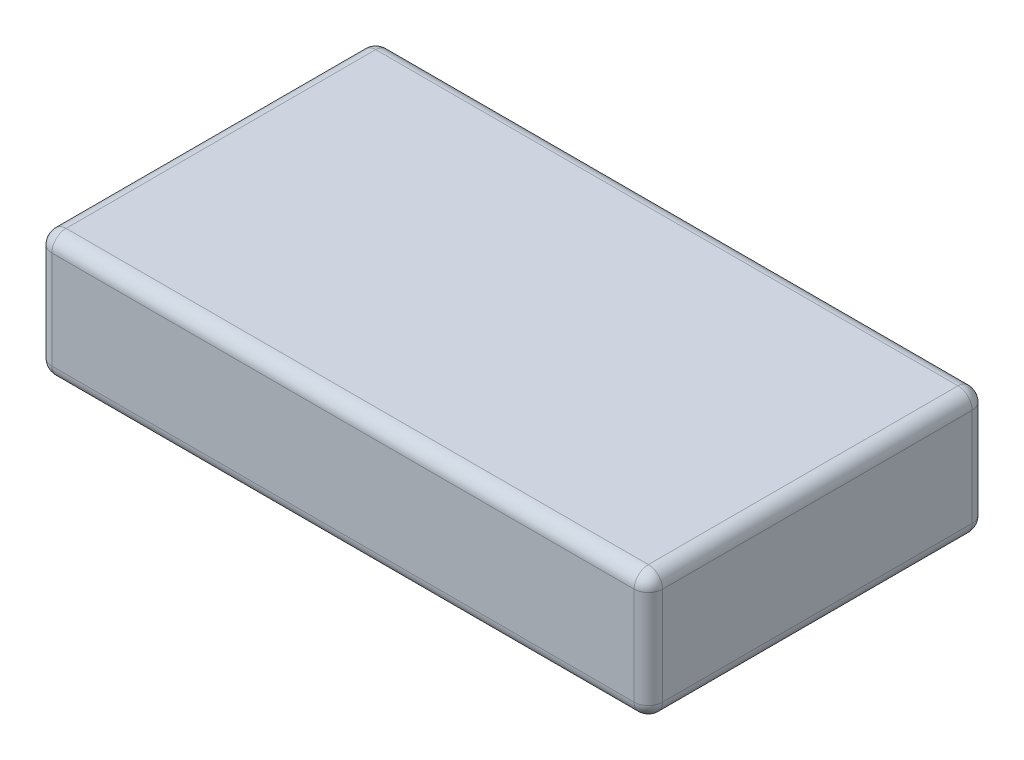
from build123d import *

# Parameters (mm, degrees)
BOSS_EXTRUDE1_DEPTH = 8.89
FILLET1_R           = 1


with BuildPart() as part:
    # Sketch1 → Boss-Extrude1 (new body)
    with BuildSketch(Plane(origin=(0, 0, 0), x_dir=(1, 0, 0), z_dir=(0, 1, 0))):
        with BuildLine():
            Line((-20.5, -11.9), (20.5, -11.9))
            ThreePointArc((20.5, -11.9), (21.207106781, -11.607106781), (21.5, -10.9))
            Line((21.5, -10.9), (21.5, 10.9))
            ThreePointArc((21.5, 10.9), (21.207106781, 11.607106781), (20.5, 11.9))
            Line((20.5, 11.9), (-20.5, 11.9))
            ThreePointArc((-20.5, 11.9), (-21.207106781, 11.607106781), (-21.5, 10.9))
            Line((-21.5, 10.9), (-21.5, -10.9))
            ThreePointArc((-21.5, -10.9), (-21.207106781, -11.607106781), (-20.5, -11.9))
        make_face()
    extrude(amount=BOSS_EXTRUDE1_DEPTH)

    # Fillet1
    fillet1_edges = [part.edges().sort_by_distance(p)[0] for p in [
        (21.207106781, 8.89, 11.607106781),
        (0, 0, 11.9),
        (-21.207106781, 0, 11.607106781),
        (21.5, 8.89, 0),
        (21.207106781, 8.89, -11.607106781),
        (0, 8.89, -11.9),
        (-21.207106781, 8.89, -11.607106781),
        (-21.5, 8.89, 0),
        (-21.207106781, 8.89, 11.607106781),
        (0, 8.89, 11.9),
        (-21.5, 0, 0),
        (-21.207106781, 0, -11.607106781),
        (0, 0, -11.9),
        (21.207106781, 0, -11.607106781),
        (21.5, 0, 0),
        (21.207106781, 0, 11.607106781),
    ]]
    fillet(fillet1_edges, radius=FILLET1_R)


solid = part.part
